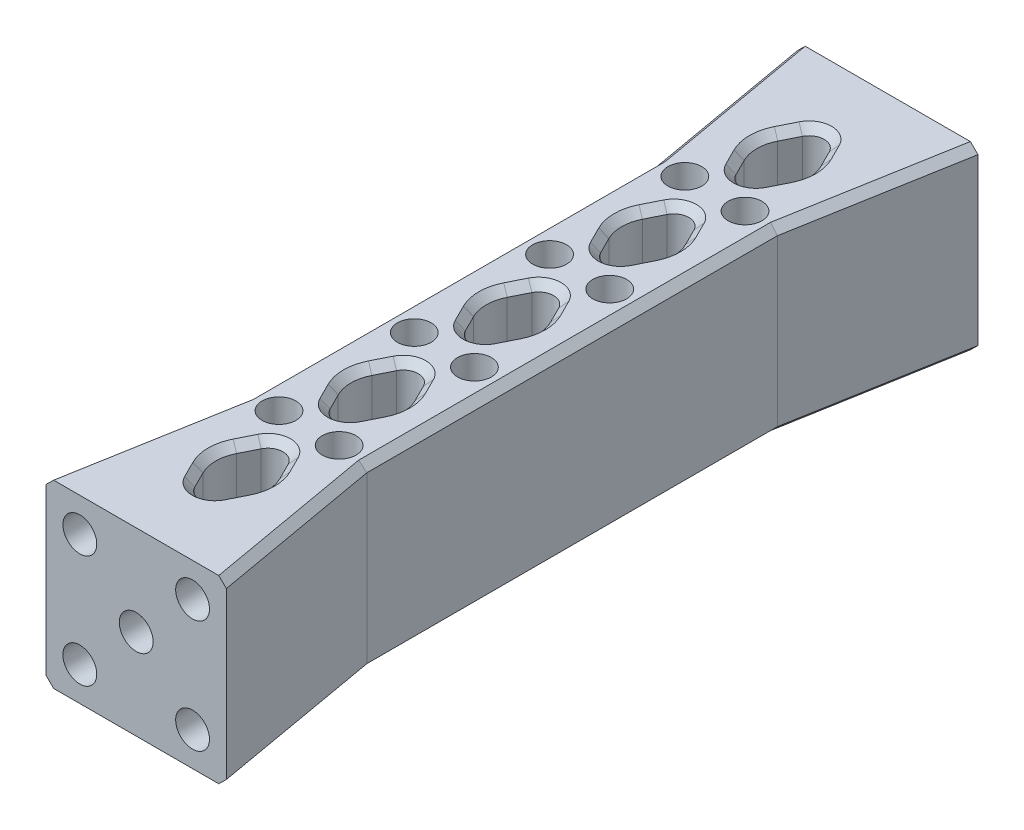
from build123d import *

# Parameters (mm, degrees)
SKETCH1_R           = 2.25
BOSS_EXTRUDE1_DEPTH = 12
FILLET1_R           = 5
CUT_EXTRUDE1_START  = 50
SKETCH2_R           = 2.25
CUT_EXTRUDE1_DEPTH  = 5
FILLET3_R           = 2
FILLET2_R           = 5
CHAMFER1_SIZE       = 1


with BuildPart() as part:
    # Sketch1 → Boss-Extrude1 (new body, symmetric)
    with BuildSketch(Plane(origin=(0, 0, 0), x_dir=(1, 0, 0), z_dir=(0, 1, 0))):
        Polygon((8, 0), (4, 0), (0, -8), (0, -10), (4, -18), (0, -26), (0, -28), (4, -36), (0, -44), (0, -50), (12, -50), (8, -27.314872722), align=None)
        with Locations((4, -27)):
            Circle(SKETCH1_R, mode=Mode.SUBTRACT)
        with Locations((4, -9)):
            Circle(SKETCH1_R, mode=Mode.SUBTRACT)
    extrude(amount=BOSS_EXTRUDE1_DEPTH, both=True)

    # Fillet1
    fillet1_edges = [part.edges().sort_by_distance(p)[0] for p in [
        (4, 0, 18),
        (4, 0, 36),
    ]]
    fillet(fillet1_edges, radius=FILLET1_R)

    # Mirror1: part across plane


with BuildPart() as part_1:
    add(part.part)
    add(part.part.mirror(Plane(origin=(0, 0, 0), x_dir=(0, 0, 1), z_dir=(1, 0, 0))))

    # Sketch2 → Cut-Extrude1 (cut)
    with BuildSketch(Plane.XY.offset(CUT_EXTRUDE1_START)):
        with Locations((-7.5, 7.5)):
            Circle(SKETCH2_R)
        Circle(SKETCH2_R)
        with Locations((7.5, 7.5)):
            Circle(SKETCH2_R)
        with Locations((7.5, -7.5)):
            Circle(SKETCH2_R)
        with Locations((-7.5, -7.5)):
            Circle(SKETCH2_R)
    extrude(amount=-CUT_EXTRUDE1_DEPTH, mode=Mode.SUBTRACT)

    # Fillet3
    fillet3_edges = [part_1.edges().sort_by_distance(p)[0] for p in [
        (0, 0, 44),
        (0, 0, 8),
        (0, 0, 10),
        (0, 0, 26),
        (0, 0, 28),
    ]]
    fillet(fillet3_edges, radius=FILLET3_R)

    # Mirror2: part across plane


with BuildPart() as part_2:
    add(part_1.part)
    add(part_1.part.mirror(Plane.XY))

    # Fillet2
    fillet2_edges = [part_2.edges().sort_by_distance(p)[0] for p in [
        (4, 0, 0),
        (-4, 0, 0),
    ]]
    fillet(fillet2_edges, radius=FILLET2_R)

    # Chamfer1
    chamfer1_edges = [part_2.edges().sort_by_distance(p)[0] for p in [
        (2.335410197, -12, 32.670820393),
        (2.335410197, 12, 32.670820393),
        (-2.335410197, -12, 32.670820393),
        (-2.335410197, 12, 32.670820393),
        (2.335410197, -12, 14.670820393),
        (2.335410197, 12, 14.670820393),
        (-2.335410197, -12, 14.670820393),
        (-2.335410197, 12, 14.670820393),
        (0, -12, 30.472135955),
        (0, 12, 30.472135955),
        (0, -12, 12.472135955),
        (0, 12, 12.472135955),
        (0, -12, 5.527864045),
        (0, 12, 5.527864045),
        (0, -12, 23.527864045),
        (0, 12, 23.527864045),
        (0, -12, 41.527864045),
        (0, 12, 41.527864045),
        (2.335410197, 12, -32.670820393),
        (2.335410197, 12, -39.329179607),
        (10, -12, -38.657436361),
        (2.335410197, 12, -14.670820393),
        (2.335410197, 12, -21.329179607),
        (-2.335410197, 12, -32.670820393),
        (-3.409830056, 12, -36),
        (-2.335410197, 12, -39.329179607),
        (10, 12, -38.657436361),
        (-2.335410197, 12, -14.670820393),
        (-3.409830056, 12, -18),
        (-2.335410197, 12, -21.329179607),
        (-3.409830056, -12, -36),
        (2.335410197, -12, -32.670820393),
        (2.335410197, -12, -39.329179607),
        (-10, -12, -38.657436361),
        (2.335410197, -12, -14.670820393),
        (2.335410197, -12, -21.329179607),
        (-3.409830056, -12, -18),
        (3.409830056, 12, -18),
        (3.409830056, -12, -18),
        (3.409830056, 12, -36),
        (3.409830056, -12, -36),
        (-2.335410197, -12, -32.670820393),
        (-2.335410197, -12, -39.329179607),
        (-10, 12, -38.657436361),
        (-2.335410197, -12, -14.670820393),
        (-2.335410197, -12, -21.329179607),
        (0, 12, -30.472135955),
        (0, -12, -30.472135955),
        (0, 12, -12.472135955),
        (0, -12, -12.472135955),
        (0, 12, -5.527864045),
        (0, -12, -5.527864045),
        (0, 12, -23.527864045),
        (0, -12, -23.527864045),
        (0, 12, -41.527864045),
        (0, -12, -41.527864045),
        (8, -12, 0),
        (10, -12, 38.657436361),
        (-2.335410197, 12, -3.329179607),
        (-2.335410197, -12, -3.329179607),
        (-2.335410197, 12, 3.329179607),
        (-2.335410197, -12, 3.329179607),
        (2.335410197, -12, 3.329179607),
        (2.335410197, 12, 3.329179607),
        (2.335410197, -12, -3.329179607),
        (2.335410197, 12, -3.329179607),
        (-3.409830056, -12, 0),
        (-3.409830056, 12, 0),
        (3.409830056, -12, 0),
        (3.409830056, 12, 0),
        (10, 12, 38.657436361),
        (8, 12, 0),
        (2.335410197, -12, 21.329179607),
        (2.335410197, 12, 21.329179607),
        (2.335410197, -12, 39.329179607),
        (2.335410197, 12, 39.329179607),
        (3.409830056, -12, 18),
        (3.409830056, 12, 18),
        (3.409830056, -12, 36),
        (3.409830056, 12, 36),
        (-2.335410197, 12, 39.329179607),
        (-10, -12, 38.657436361),
        (-8, -12, 0),
        (-2.335410197, 12, 21.329179607),
        (-8, 12, 0),
        (-10, 12, 38.657436361),
        (-2.335410197, -12, 39.329179607),
        (-2.335410197, -12, 21.329179607),
        (-3.409830056, 12, 18),
        (-3.409830056, -12, 18),
        (-3.409830056, 12, 36),
        (-3.409830056, -12, 36),
    ]]
    chamfer(chamfer1_edges, length=CHAMFER1_SIZE)


solid = part_2.part
